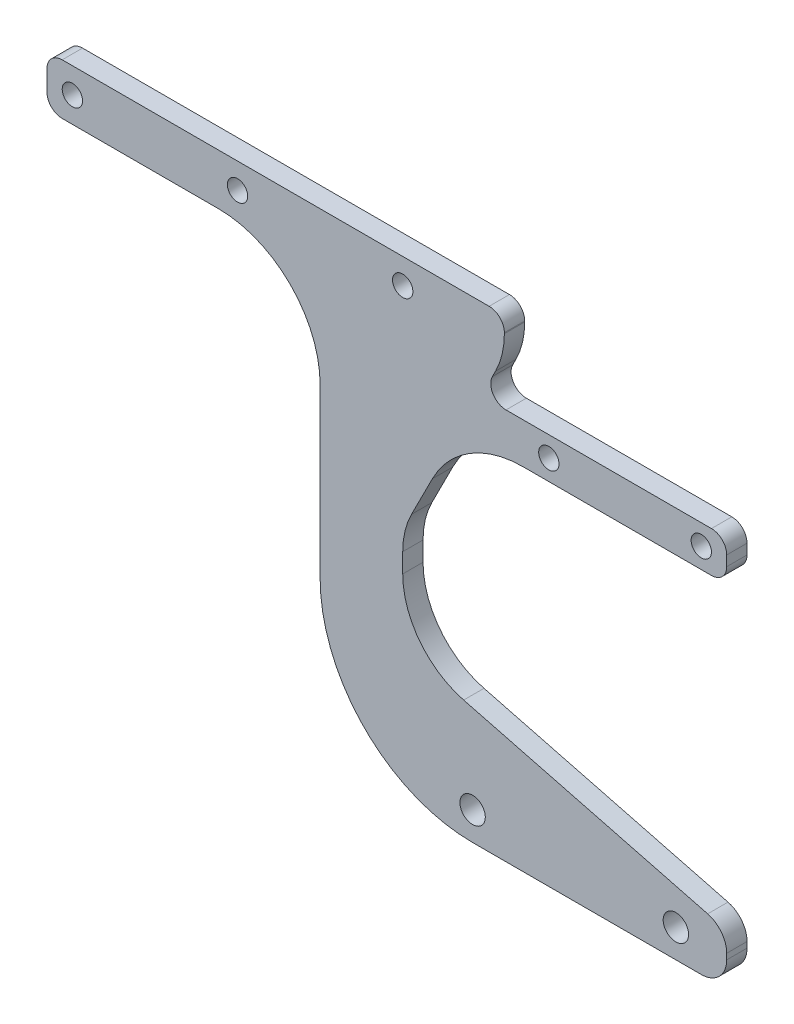
from build123d import *

# Parameters (mm, degrees)
SKETCH1_R           = 2
SKETCH1_R_2         = 2.5
SKETCH1_R_3         = 2.001
BOSS_EXTRUDE1_DEPTH = 4


with BuildPart() as part:
    # Sketch1 → Boss-Extrude1 (new body)
    with BuildSketch(Plane.XY):
        with BuildLine():
            Line((3, 0), (33.75, 0))
            ThreePointArc((33.75, 0), (47.892135624, -5.857864376), (53.75, -20))
            Line((53.75, -20), (53.75, -53))
            ThreePointArc((53.75, -53), (62.536796564, -74.213203436), (83.75, -83))
            Line((83.75, -83), (128.75, -83))
            ThreePointArc((128.75, -83), (132.285533906, -81.535533906), (133.75, -78))
            Line((133.75, -78), (133.75, -76.870641833))
            ThreePointArc((133.75, -76.870641833), (132.703743283, -73.809937003), (130.002834379, -72.030145369))
            Line((130.002834379, -72.030145369), (81.990929987, -59.60353482))
            ThreePointArc((81.990929987, -59.60353482), (73.348021495, -53.908201589), (70, -44.113946135))
            Line((70, -44.113946135), (70, -40.319768492))
            ThreePointArc((70, -40.319768492), (70.437348676, -36.604410668), (71.72548547, -33.092166198))
            Line((71.72548547, -33.092166198), (75.840254616, -24.965497133))
            ThreePointArc((75.840254616, -24.965497133), (83.211770813, -16.960486255), (93.68339778, -14))
            Line((93.68339778, -14), (130.751, -14))
            ThreePointArc((130.751, -14), (132.871613237, -13.121613237), (133.75, -11.001))
            Line((133.75, -11.001), (133.75, -8.999))
            ThreePointArc((133.75, -8.999), (132.871613237, -6.878386763), (130.751, -6))
            Line((130.751, -6), (90.323034358, -6))
            ThreePointArc((90.323034358, -6), (87.767959272, -4.571220464), (87.64745504, -1.646276295))
            Line((87.64745504, -1.646276295), (88.27451453, -0.407833802))
            ThreePointArc((88.27451453, -0.407833802), (89.562651324, 3.104410668), (90, 6.819768492))
            Line((90, 6.819768492), (90, 7))
            ThreePointArc((90, 7), (89.121320344, 9.121320344), (87, 10))
            Line((87, 10), (3, 10))
            ThreePointArc((3, 10), (0.878679656, 9.121320344), (0, 7))
            Line((0, 7), (0, 3))
            ThreePointArc((0, 3), (0.878679656, 0.878679656), (3, 0))
        make_face()
        with Locations((5, 5)):
            Circle(SKETCH1_R, mode=Mode.SUBTRACT)
        with Locations((37.5, 5)):
            Circle(SKETCH1_R, mode=Mode.SUBTRACT)
        with Locations((70, 5)):
            Circle(SKETCH1_R, mode=Mode.SUBTRACT)
        with Locations((83.75, -77.435320916)):
            Circle(SKETCH1_R_2, mode=Mode.SUBTRACT)
        with Locations((123.75, -77.435320916)):
            Circle(SKETCH1_R_2, mode=Mode.SUBTRACT)
        with Locations((128.75, -10)):
            Circle(SKETCH1_R_3, mode=Mode.SUBTRACT)
        with Locations((98.75, -10)):
            Circle(SKETCH1_R_3, mode=Mode.SUBTRACT)
    extrude(amount=BOSS_EXTRUDE1_DEPTH)


solid = part.part
